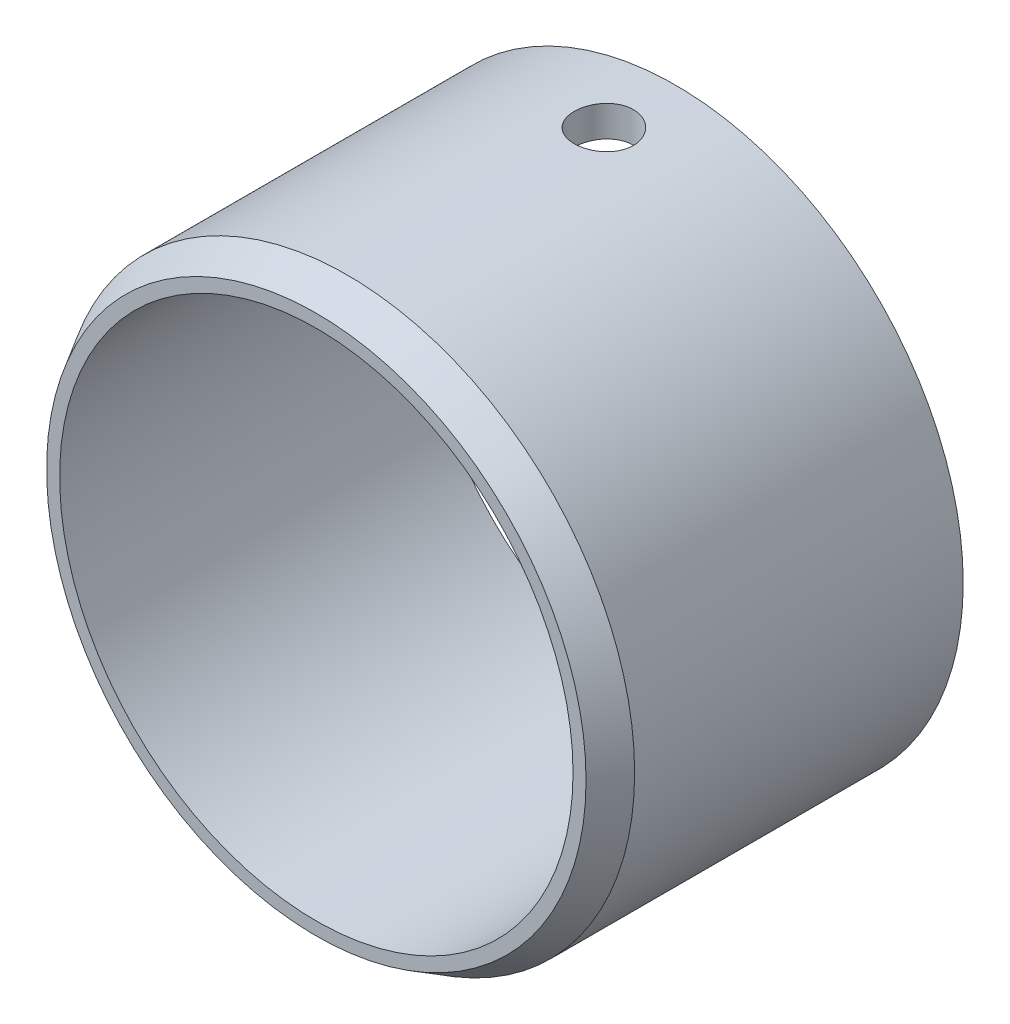
from build123d import *

# Parameters (mm, degrees)
SKETCH1_R                       = 17.78
SKETCH1_R_2                     = 15.875
BOSS_EXTRUDE1_DEPTH             = 22.225
CHAMFER4_SIZE                   = 1.905
CHAMFER4_SIZE2                  = 1.099852263
F_27_0_144_DIAMETER_HOLE1_D     = 3.6576
F_27_0_144_DIAMETER_HOLE1_DEPTH = 25.4
F_27_0_144_DIAMETER_HOLE1_TIP   = 1.0988539


with BuildPart() as part:
    # Sketch1 → Boss-Extrude1 (new body)
    with BuildSketch(Plane.XY):
        Circle(SKETCH1_R)
        Circle(SKETCH1_R_2, mode=Mode.SUBTRACT)
    extrude(amount=BOSS_EXTRUDE1_DEPTH)

    # Chamfer4
    chamfer4_edges = [part.edges().sort_by_distance(p)[0] for p in [
        (-17.78, 0, 22.225),
    ]]
    chamfer4_side = [part.faces().sort_by_distance(p)[0] for p in [
        (-17.78, 0, 11.1125),
    ]]
    chamfer(chamfer4_edges, length=CHAMFER4_SIZE, length2=CHAMFER4_SIZE2, reference=chamfer4_side[0])

    # #27 (0.144) Diameter Hole1
    with Locations(Plane(origin=(0, 17.78, 4.445), x_dir=(1, 0, 0), z_dir=(0, 1, 0))):
        with Locations((0, 0)):
            Hole(F_27_0_144_DIAMETER_HOLE1_D / 2, depth=F_27_0_144_DIAMETER_HOLE1_DEPTH)
            with Locations((0, 0, -(F_27_0_144_DIAMETER_HOLE1_DEPTH + F_27_0_144_DIAMETER_HOLE1_TIP / 2))):  # 118° drill point
                Cone(0, F_27_0_144_DIAMETER_HOLE1_D / 2, F_27_0_144_DIAMETER_HOLE1_TIP, mode=Mode.SUBTRACT)


solid = part.part
